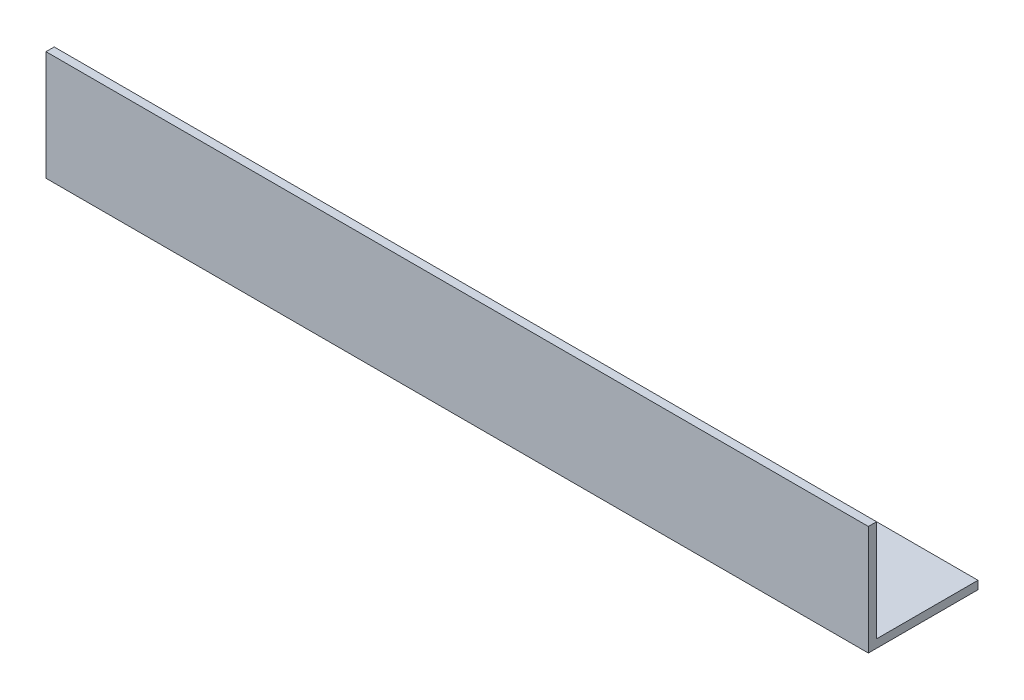
from build123d import *

# Parameters (mm, degrees)
EXTRUDE_1_DEPTH = 300


with BuildPart() as part:
    # Эскиз1 → Вытянуть-Тонкостенный1 (new body)
    with BuildSketch(Plane(origin=(0, 0, 0), x_dir=(0, 0, -1), z_dir=(1, 0, 0))):
        Polygon((40, 0), (0, 0), (0, 40), (3, 40), (3, 3), (40, 3), align=None)
    extrude(amount=EXTRUDE_1_DEPTH)


solid = part.part
